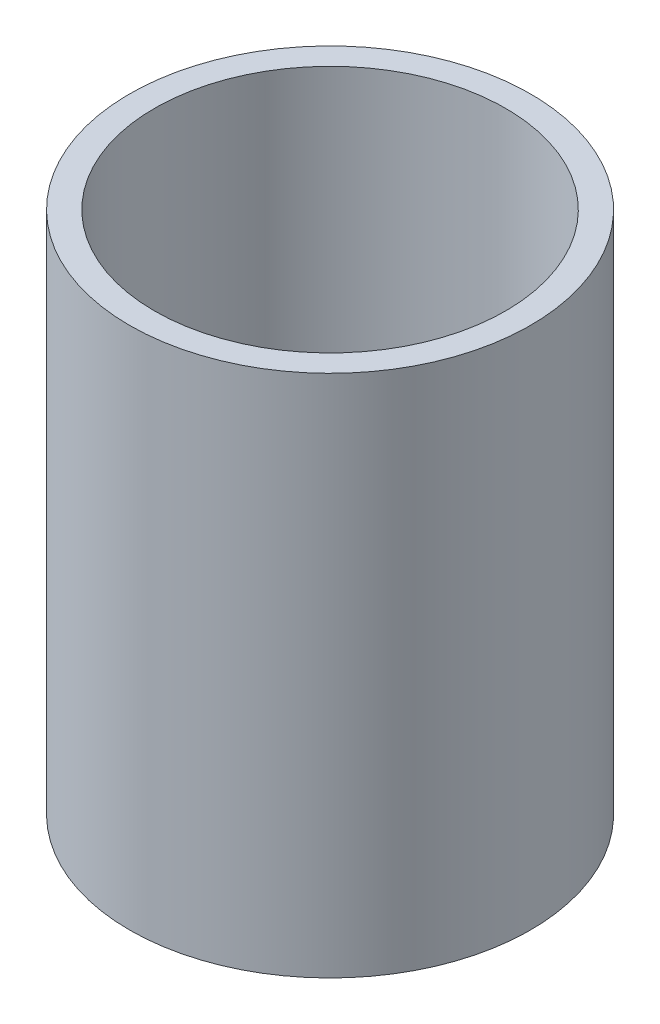
from build123d import *

# Parameters (mm, degrees)
SKETCH1_W = 6.35
SKETCH1_H = 133.35


with BuildPart() as part:
    # Sketch1 → Revolve1 (revolve)
    with BuildSketch(Plane.XY):
        with Locations((-47.879, -21.057365567)):
            Rectangle(SKETCH1_W, SKETCH1_H)
    revolve(axis=Axis((0, 55, 0), (0, -1, 0)))


solid = part.part
